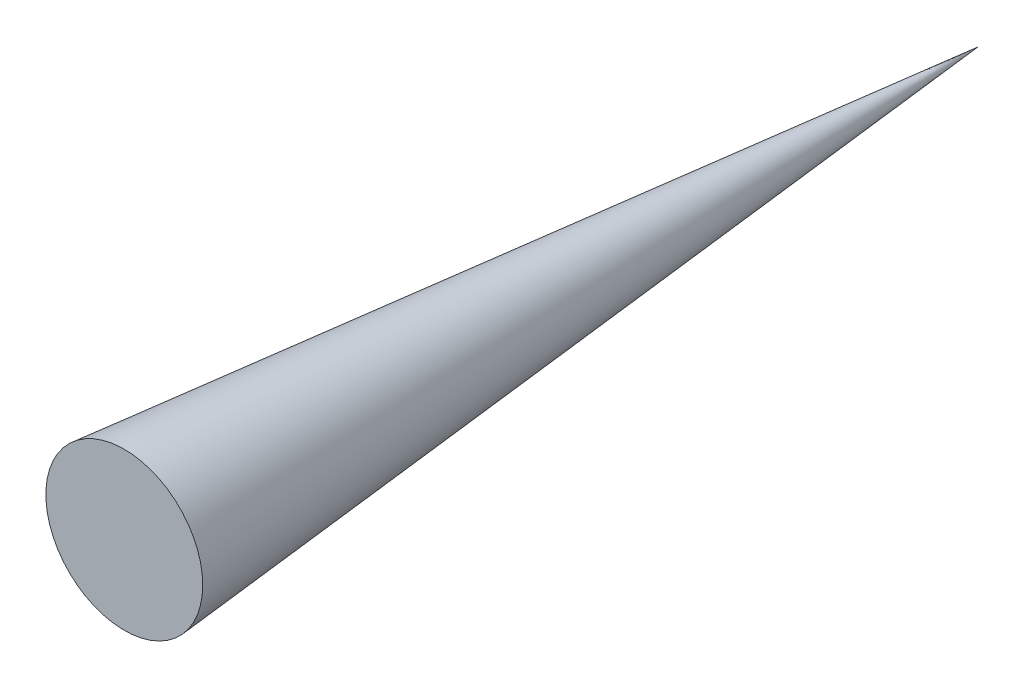
from build123d import *


with BuildPart() as part:
    # Sketch1 → Revolve1 (revolve)
    with BuildSketch(Plane(origin=(0, 0, 0), x_dir=(1, 0, 0), z_dir=(0, 1, 0))):
        Polygon((0, 0), (-30, 0), (0, 326.5), align=None)
    revolve(axis=Axis((0, 0, 33.992998997), (0, 0, -1)))


solid = part.part
